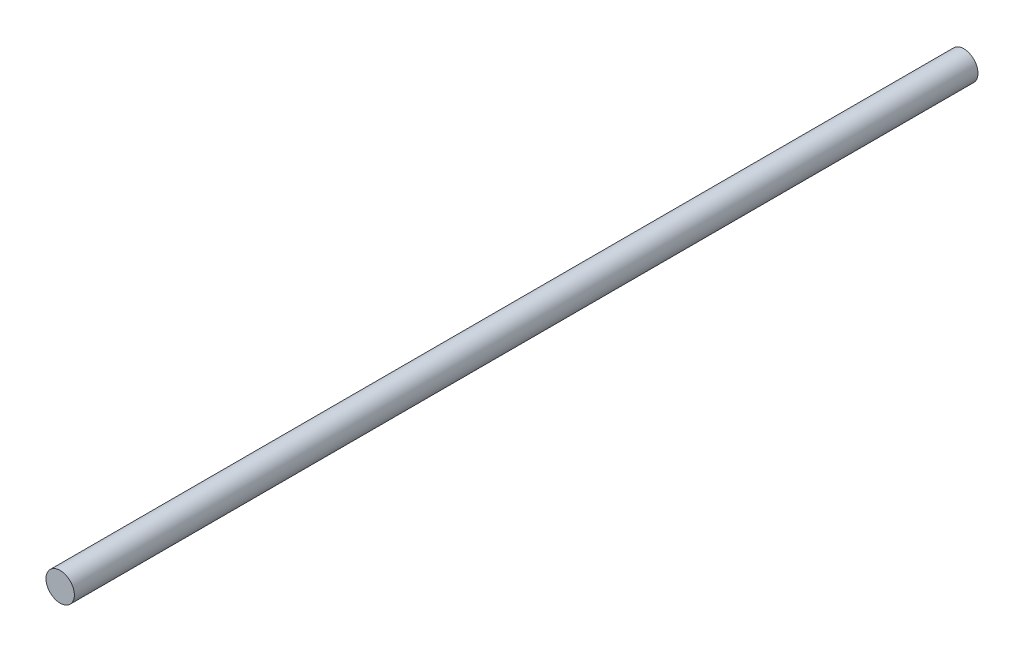
from build123d import *

# Parameters (mm, degrees)
SKETCH1_R           = 3
BOSS_EXTRUDE1_DEPTH = 191


with BuildPart() as part:
    # Sketch1 → Boss-Extrude1 (new body)
    with BuildSketch(Plane.XY):
        Circle(SKETCH1_R)
    extrude(amount=BOSS_EXTRUDE1_DEPTH)


solid = part.part
